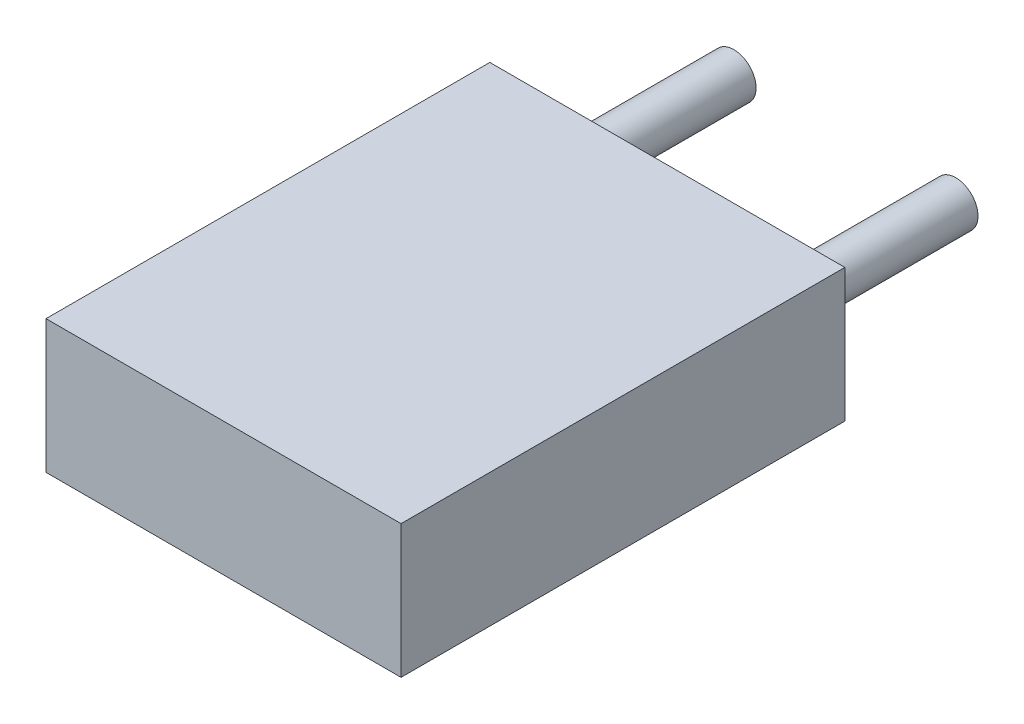
from build123d import *

# Parameters (mm, degrees)
SKETCH1_W               = 4
SKETCH1_H               = 1.5
COMPONENT_OUTLINE_DEPTH = 5
SKETCH2_R               = 0.25
EXTRUDE_1_DEPTH         = 2
SKETCH3_R               = 0.25
EXTRUDE_2_DEPTH         = 2


with BuildPart() as part:
    # Sketch1 → Component_Outline (new body)
    with BuildSketch(Plane.XY):
        with Locations((1.25, 0)):
            Rectangle(SKETCH1_W, SKETCH1_H)
    extrude(amount=COMPONENT_OUTLINE_DEPTH)


with BuildPart() as body_2:
    # Sketch2 → Extrude 1 (new body)
    with BuildSketch(Plane.XY):
        Circle(SKETCH2_R)
    extrude(amount=-EXTRUDE_1_DEPTH)


with BuildPart() as body_3:
    # Sketch3 → Extrude 2 (new body)
    with BuildSketch(Plane.XY):
        with Locations((2.5, 0)):
            Circle(SKETCH3_R)
    extrude(amount=-EXTRUDE_2_DEPTH)


solid = Compound([part.part, body_2.part, body_3.part])
